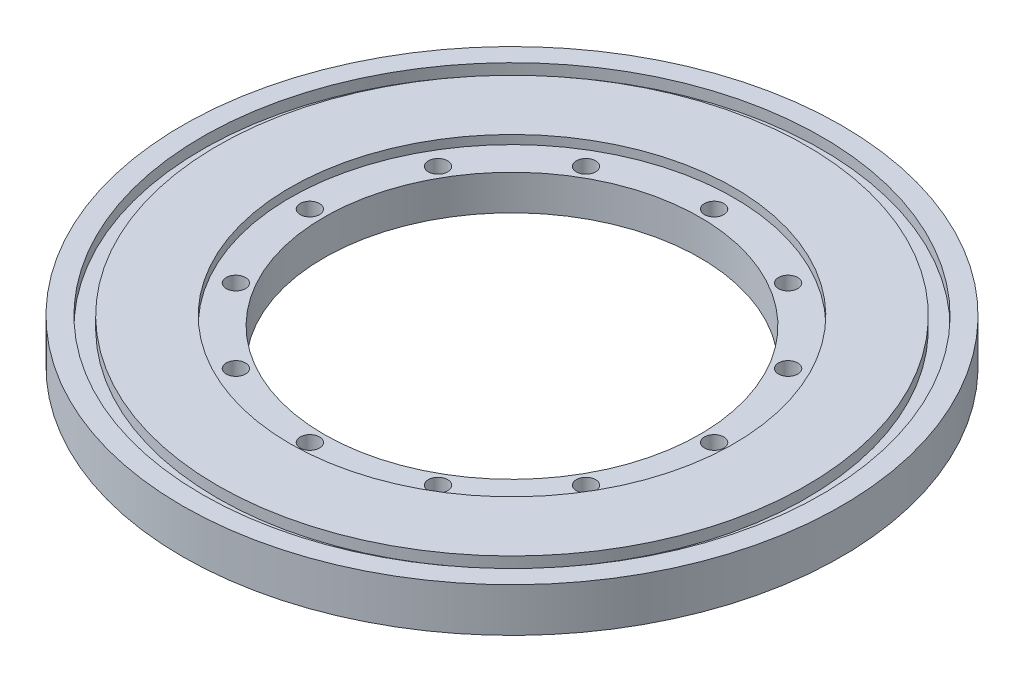
from build123d import *

# Parameters (mm, degrees)
SKETCH1_R           = 95.25
BOSS_EXTRUDE1_DEPTH = 12.7
SKETCH2_R           = 54.356
CUT_EXTRUDE1_DEPTH  = 13.7
SKETCH3_R           = 64.135
CUT_EXTRUDE2_DEPTH  = 2.54
SKETCH4_R           = 2.794
CUT_EXTRUDE3_DEPTH  = 13.7
CIRPATTERN1_COUNT   = 12
SKETCH5_R           = 89.535
SKETCH5_R_2         = 85.09
CUT_EXTRUDE4_DEPTH  = 3.175


with BuildPart() as part:
    # Sketch1 → Boss-Extrude1 (new body)
    with BuildSketch(Plane(origin=(0, 0, 0), x_dir=(1, 0, 0), z_dir=(0, 1, 0))):
        Circle(SKETCH1_R)
    extrude(amount=BOSS_EXTRUDE1_DEPTH)

    # Sketch2 → Cut-Extrude1 (cut, through all)
    with BuildSketch(Plane(origin=(0, 12.7, 0), x_dir=(1, 0, 0), z_dir=(0, 1, 0))):
        Circle(SKETCH2_R)
    extrude(amount=-CUT_EXTRUDE1_DEPTH, mode=Mode.SUBTRACT)

    # Sketch3 → Cut-Extrude2 (cut)
    with BuildSketch(Plane(origin=(0, 12.7, 0), x_dir=(1, 0, 0), z_dir=(0, 1, 0))):
        Circle(SKETCH3_R)
    extrude(amount=-CUT_EXTRUDE2_DEPTH, mode=Mode.SUBTRACT)

    # Sketch4 → Cut-Extrude3 (cut, through all)
    with BuildSketch(Plane(origin=(0, 12.7, 0), x_dir=(1, 0, 0), z_dir=(0, 1, 0))):
        with Locations((0, 58.42)):
            Circle(SKETCH4_R)
    cut_extrude3 = extrude(amount=-CUT_EXTRUDE3_DEPTH, mode=Mode.SUBTRACT)

    # CirPattern1: Cut-Extrude3 ×12 about axis
    cirpattern1_axis = Axis((0, 0, 0), (0, 1, 0))
    for i in range(1, CIRPATTERN1_COUNT):
        add(cut_extrude3.rotate(cirpattern1_axis, i * 360 / CIRPATTERN1_COUNT), mode=Mode.SUBTRACT)

    # Sketch5 → Cut-Extrude4 (cut)
    with BuildSketch(Plane(origin=(0, 12.7, 0), x_dir=(1, 0, 0), z_dir=(0, 1, 0))):
        Circle(SKETCH5_R)
        Circle(SKETCH5_R_2, mode=Mode.SUBTRACT)
    extrude(amount=-CUT_EXTRUDE4_DEPTH, mode=Mode.SUBTRACT)


solid = part.part
